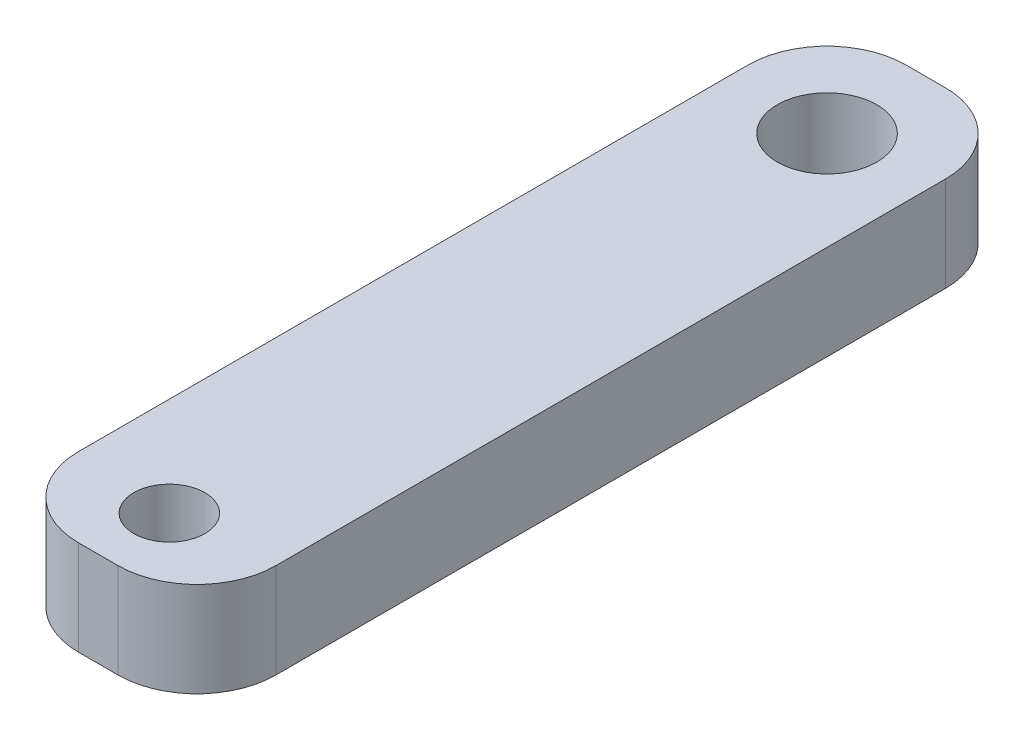
from build123d import *

# Parameters (mm, degrees)
SKETCH1_R           = 1.6
SKETCH1_R_2         = 1.143
BOSS_EXTRUDE1_DEPTH = 3.048


with BuildPart() as part:
    # Sketch1 → Boss-Extrude1 (new body)
    with BuildSketch(Plane(origin=(0, 80.955025863, 0), x_dir=(1, 0, 0), z_dir=(0, 1, 0))):
        with BuildLine():
            Line((142.437898145, -152.525300586), (143.707898145, -152.525300586))
            ThreePointArc((143.707898145, -152.525300586), (145.503949369, -153.269249361), (146.247898145, -155.065300586))
            Line((146.247898145, -155.065300586), (146.247898145, -176.598461023))
            ThreePointArc((146.247898145, -176.598461023), (145.503949369, -178.394512247), (143.707898145, -179.138461023))
            Line((143.707898145, -179.138461023), (142.437898145, -179.138461023))
            ThreePointArc((142.437898145, -179.138461023), (140.641846921, -178.394512247), (139.897898145, -176.598461023))
            Line((139.897898145, -176.598461023), (139.897898145, -155.065300586))
            ThreePointArc((139.897898145, -155.065300586), (140.641846921, -153.269249361), (142.437898145, -152.525300586))
        make_face()
        with Locations((143.072898145, -155.700300586)):
            Circle(SKETCH1_R, mode=Mode.SUBTRACT)
        with Locations((143.072898145, -176.852461023)):
            Circle(SKETCH1_R_2, mode=Mode.SUBTRACT)
    extrude(amount=BOSS_EXTRUDE1_DEPTH)


solid = part.part
